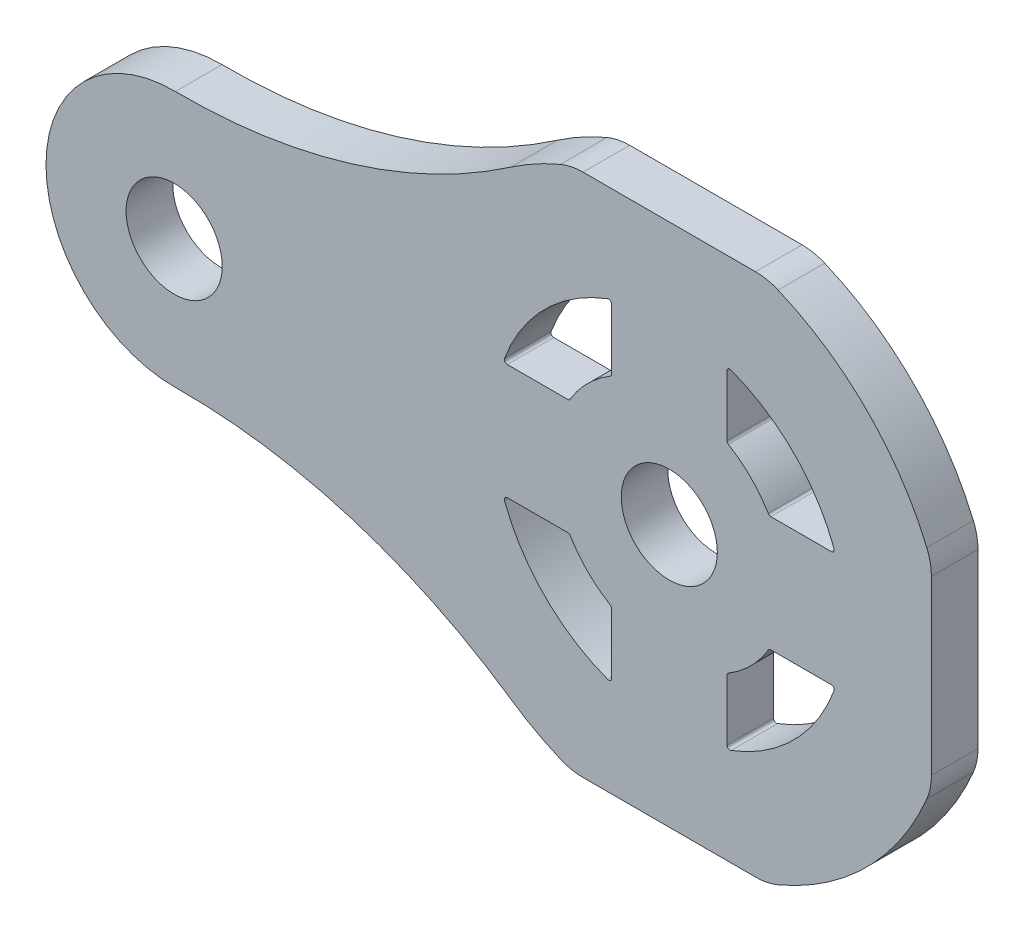
from build123d import *

# Parameters (mm, degrees)
SKETCH1_R          = 8.25
BASE_EXTRUDE_DEPTH = 8


with BuildPart() as part:
    # Sketch1 → Base-Extrude (new body)
    with BuildSketch(Plane.XY):
        with BuildLine():
            Line((45, 14.798648587), (45, -14.798648587))
            ThreePointArc((45, -14.798648587), (44.800644447, -16.785447123), (44.210526316, -18.693029794))
            ThreePointArc((44.210526316, -18.693029794), (33.941125497, -33.941125497), (18.693029794, -44.210526316))
            ThreePointArc((18.693029794, -44.210526316), (16.785447123, -44.800644447), (14.798648587, -45))
            Line((14.798648587, -45), (-14.798648587, -45))
            ThreePointArc((-14.798648587, -45), (-16.785447123, -44.800644447), (-18.693029794, -44.210526316))
            ThreePointArc((-18.693029794, -44.210526316), (-23.05203941, -42.102297788), (-27.176470588, -39.565634664))
            ThreePointArc((-27.176470588, -39.565634664), (-54.625644624, -26.342588675), (-84.782545805, -21.998925285))
            ThreePointArc((-84.782545805, -21.998925285), (-100.479276593, -15.633041807), (-107, 0))
            ThreePointArc((-107, 0), (-100.479276593, 15.633041807), (-84.782545805, 21.998925285))
            ThreePointArc((-84.782545805, 21.998925285), (-54.625644624, 26.342588675), (-27.176470588, 39.565634664))
            ThreePointArc((-27.176470588, 39.565634664), (-23.05203941, 42.102297788), (-18.693029794, 44.210526316))
            ThreePointArc((-18.693029794, 44.210526316), (-16.785447123, 44.800644447), (-14.798648587, 45))
            Line((-14.798648587, 45), (14.798648587, 45))
            ThreePointArc((14.798648587, 45), (16.785447123, 44.800644447), (18.693029794, 44.210526316))
            ThreePointArc((18.693029794, 44.210526316), (33.941125497, 33.941125497), (44.210526316, 18.693029794))
            ThreePointArc((44.210526316, 18.693029794), (44.800644447, 16.785447123), (45, 14.798648587))
        make_face()
        with Locations((-85, 0)):
            Circle(SKETCH1_R, mode=Mode.SUBTRACT)
        Circle(SKETCH1_R, mode=Mode.SUBTRACT)
        with BuildLine():
            Line((-9.9, 27.819597409), (-9.9, 17.433588271))
            ThreePointArc((-9.9, 17.433588271), (-9.965213375, 17.186686284), (-10.143842365, 17.004189545))
            ThreePointArc((-10.143842365, 17.004189545), (-14.000714267, 14.000714267), (-17.004189545, 10.143842365))
            ThreePointArc((-17.004189545, 10.143842365), (-17.186686284, 9.965213375), (-17.433588271, 9.9))
            Line((-17.433588271, 9.9), (-27.819597409, 9.9))
            ThreePointArc((-27.819597409, 9.9), (-28.23041494, 10.114993059), (-28.2879408, 10.575084175))
            ThreePointArc((-28.2879408, 10.575084175), (-21.354624792, 21.354624792), (-10.575084175, 28.2879408))
            ThreePointArc((-10.575084175, 28.2879408), (-10.114993059, 28.23041494), (-9.9, 27.819597409))
        make_face(mode=Mode.SUBTRACT)
        with BuildLine():
            Line((17.433588271, 9.9), (27.819597409, 9.9))
            ThreePointArc((27.819597409, 9.9), (28.23041494, 10.114993059), (28.2879408, 10.575084175))
            ThreePointArc((28.2879408, 10.575084175), (21.354624792, 21.354624792), (10.575084175, 28.2879408))
            ThreePointArc((10.575084175, 28.2879408), (10.114993059, 28.23041494), (9.9, 27.819597409))
            Line((9.9, 27.819597409), (9.9, 17.433588271))
            ThreePointArc((9.9, 17.433588271), (9.965213375, 17.186686284), (10.143842365, 17.004189545))
            ThreePointArc((10.143842365, 17.004189545), (14.000714267, 14.000714267), (17.004189545, 10.143842365))
            ThreePointArc((17.004189545, 10.143842365), (17.186686284, 9.965213375), (17.433588271, 9.9))
        make_face(mode=Mode.SUBTRACT)
        with BuildLine():
            Line((9.9, -27.819597409), (9.9, -17.433588271))
            ThreePointArc((9.9, -17.433588271), (9.965213375, -17.186686284), (10.143842365, -17.004189545))
            ThreePointArc((10.143842365, -17.004189545), (14.000714267, -14.000714267), (17.004189545, -10.143842365))
            ThreePointArc((17.004189545, -10.143842365), (17.186686284, -9.965213375), (17.433588271, -9.9))
            Line((17.433588271, -9.9), (27.819597409, -9.9))
            ThreePointArc((27.819597409, -9.9), (28.23041494, -10.114993059), (28.2879408, -10.575084175))
            ThreePointArc((28.2879408, -10.575084175), (21.354624792, -21.354624792), (10.575084175, -28.2879408))
            ThreePointArc((10.575084175, -28.2879408), (10.114993059, -28.23041494), (9.9, -27.819597409))
        make_face(mode=Mode.SUBTRACT)
        with BuildLine():
            Line((-17.433588271, -9.9), (-27.819597409, -9.9))
            ThreePointArc((-27.819597409, -9.9), (-28.23041494, -10.114993059), (-28.2879408, -10.575084175))
            ThreePointArc((-28.2879408, -10.575084175), (-21.354624792, -21.354624792), (-10.575084175, -28.2879408))
            ThreePointArc((-10.575084175, -28.2879408), (-10.114993059, -28.23041494), (-9.9, -27.819597409))
            Line((-9.9, -27.819597409), (-9.9, -17.433588271))
            ThreePointArc((-9.9, -17.433588271), (-9.965213375, -17.186686284), (-10.143842365, -17.004189545))
            ThreePointArc((-10.143842365, -17.004189545), (-14.000714267, -14.000714267), (-17.004189545, -10.143842365))
            ThreePointArc((-17.004189545, -10.143842365), (-17.186686284, -9.965213375), (-17.433588271, -9.9))
        make_face(mode=Mode.SUBTRACT)
    extrude(amount=BASE_EXTRUDE_DEPTH)


solid = part.part
